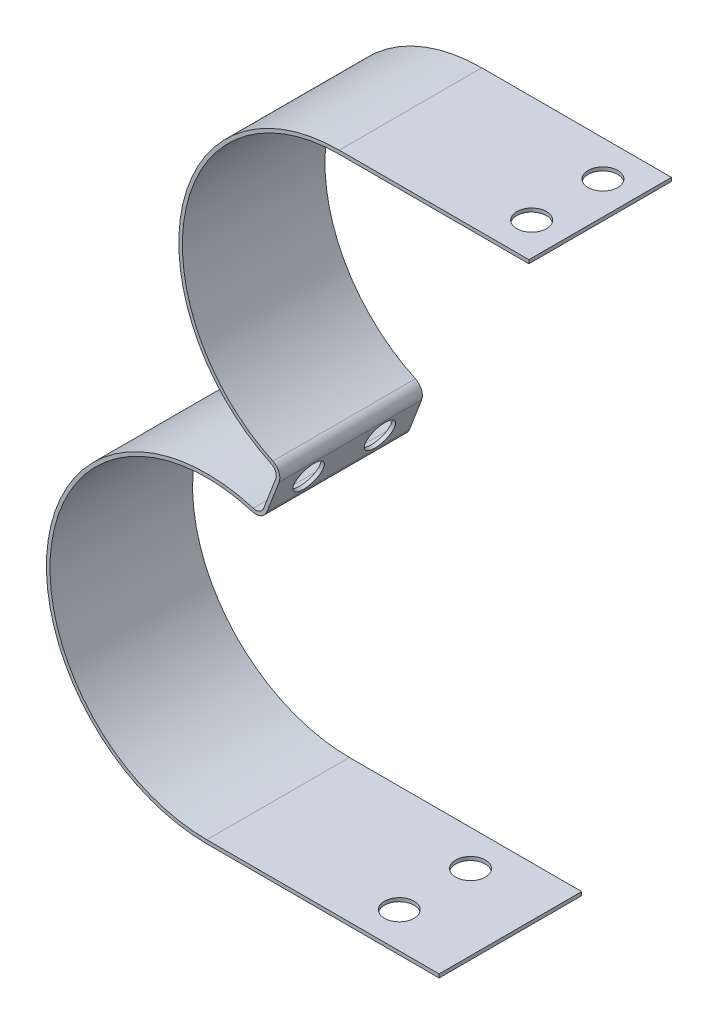
from build123d import *

# Parameters (mm, degrees)
BOSS_EXTRUDE1_DEPTH = 31.75
SKETCH2_R           = 3.302
CUT_EXTRUDE1_DEPTH  = 81.553334057
SKETCH3_R           = 3.302
CUT_EXTRUDE2_DEPTH  = 31.75
SKETCH4_R           = 3.302
CUT_EXTRUDE3_DEPTH  = 31.75
FILLET1_R           = 1.905
FILLET2_R           = 2.69875


with BuildPart() as part:
    # Sketch1 → Boss-Extrude1 (new body)
    with BuildSketch(Plane.XY):
        with BuildLine():
            Line((-17.009825212, -44.483777619), (-12.473871822, -32.621436921))
            ThreePointArc((-12.473871822, -32.621436921), (-34.344281252, 6.34239468), (0, 34.925))
            Line((0, 34.925), (42.249880176, 34.925))
            Line((42.249880176, 34.925), (42.249880176, 35.71875))
            Line((42.249880176, 35.71875), (0, 35.71875))
            ThreePointArc((0, 35.71875), (-35.050587448, 6.876439568), (-13.495614846, -33.071097373))
            Line((-13.495614846, -33.071097373), (-17.470874776, -43.467122992))
            ThreePointArc((-17.470874776, -43.467122992), (-64.678438716, -71.009375011), (-29.483697034, -112.82396454))
            Line((-29.483697034, -112.82396454), (22.258027731, -112.82396454))
            Line((22.258027731, -112.82396454), (22.258027731, -112.03021454))
            Line((22.258027731, -112.03021454), (-29.483697034, -112.03021454))
            ThreePointArc((-29.483697034, -112.03021454), (-63.827978286, -70.76281986), (-17.009825212, -44.483777619))
        make_face()
    extrude(amount=BOSS_EXTRUDE1_DEPTH)

    # Sketch2 → Cut-Extrude1 (cut, through all)
    with BuildSketch(Plane(origin=(-0.741396294, 0.283497087, 0), x_dir=(0, 0, 1), z_dir=(-0.934042575, 0.357161684, 0))):
        with Locations((7.9375, -41.275)):
            Circle(SKETCH2_R)
        with Locations((23.8125, -41.275)):
            Circle(SKETCH2_R)
    extrude(amount=-CUT_EXTRUDE1_DEPTH, mode=Mode.SUBTRACT)

    # Sketch3 → Cut-Extrude2 (cut)
    with BuildSketch(Plane(origin=(0, 35.71875, 0), x_dir=(1, 0, 0), z_dir=(0, 1, 0))):
        with Locations((34.925, -7.9375)):
            Circle(SKETCH3_R)
        with Locations((34.925, -23.8125)):
            Circle(SKETCH3_R)
    extrude(amount=-CUT_EXTRUDE2_DEPTH, mode=Mode.SUBTRACT)

    # Sketch4 → Cut-Extrude3 (cut)
    with BuildSketch(Plane.XZ.offset(112.82396454)):
        with Locations((5.441302966, 23.8125)):
            Circle(SKETCH4_R)
        with Locations((5.441302966, 7.9375)):
            Circle(SKETCH4_R)
    extrude(amount=-CUT_EXTRUDE3_DEPTH, mode=Mode.SUBTRACT)

    # Fillet1
    fillet1_edges = [part.edges().sort_by_distance(p)[0] for p in [
        (-17.470874776, -43.467122992, 15.875),
        (-13.495614846, -33.071097373, 15.875),
    ]]
    fillet(fillet1_edges, radius=FILLET1_R)

    # Fillet2
    fillet2_edges = [part.edges().sort_by_distance(p)[0] for p in [
        (-12.473871822, -32.621436921, 15.875),
        (-17.009825212, -44.483777619, 15.875),
    ]]
    fillet(fillet2_edges, radius=FILLET2_R)


solid = part.part
